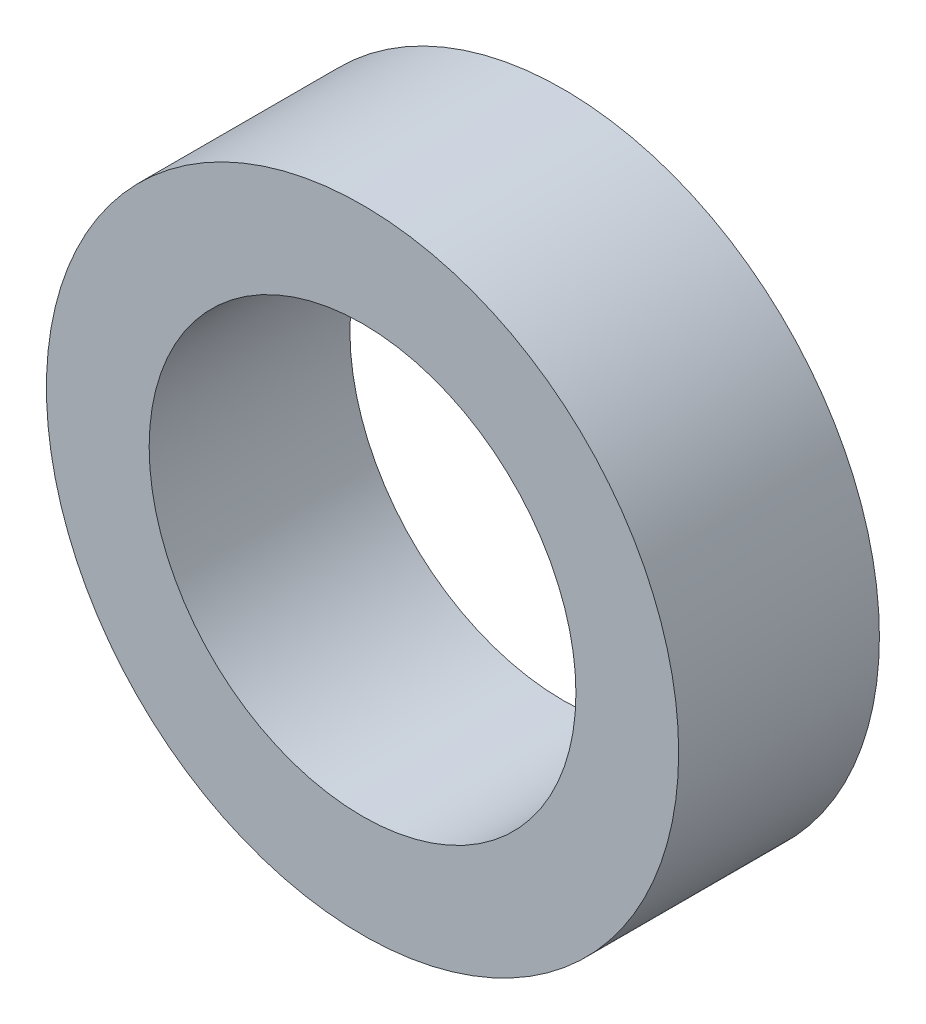
from build123d import *

# Parameters (mm, degrees)
SKETCH1_R           = 4
SKETCH1_R_2         = 2.7
BOSS_EXTRUDE2_DEPTH = 2.54


with BuildPart() as part:
    # Sketch1 → Boss-Extrude2 (new body)
    with BuildSketch(Plane.XY):
        Circle(SKETCH1_R)
        Circle(SKETCH1_R_2, mode=Mode.SUBTRACT)
    extrude(amount=BOSS_EXTRUDE2_DEPTH)


solid = part.part
